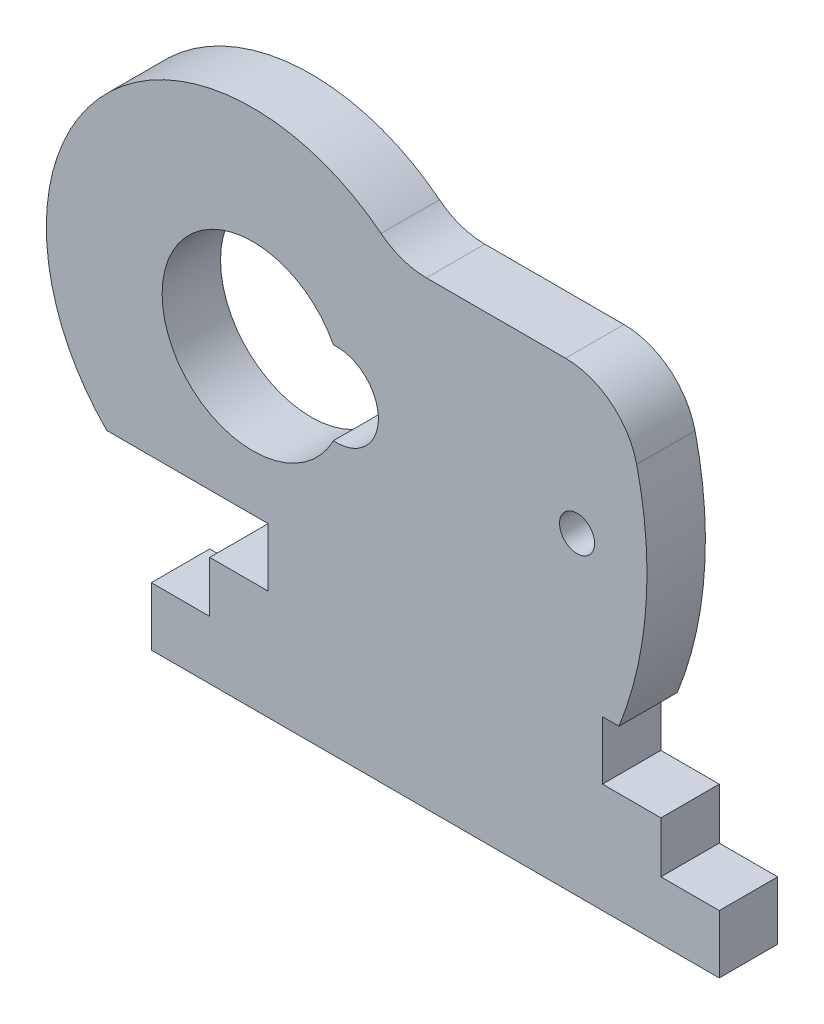
from build123d import *

# Parameters (mm, degrees)
SKETCH2_R           = 1.2
BOSS_EXTRUDE1_DEPTH = 4
FILLET1_R           = 5


with BuildPart() as part:
    # Sketch2 → Boss-Extrude1 (new body)
    with BuildSketch(Plane.XY):
        with BuildLine():
            Line((0, 4), (0, 0))
            Line((0, 0), (38.9, 0))
            Line((38.9, 0), (38.9, 4))
            Line((38.9, 4), (34.9, 4))
            Line((34.9, 4), (34.9, 7.5))
            Line((34.9, 7.5), (30.9, 7.5))
            Line((30.9, 7.5), (30.9, 11.5))
            Line((30.9, 11.5), (32.029872408, 11.5))
            ThreePointArc((32.029872408, 11.5), (33.95, 21.5), (32.029872408, 31.5))
            Line((32.029872408, 31.5), (16.95, 31.5))
            ThreePointArc((16.95, 31.5), (-3.05, 31.5), (-3.05, 11.5))
            Line((-3.05, 11.5), (8, 11.5))
            Line((8, 11.5), (8, 7.5))
            Line((8, 7.5), (4, 7.5))
            Line((4, 7.5), (4, 4))
            Line((4, 4), (0, 4))
        make_face()
        with BuildLine():
            ThreePointArc((12.472095652, 24.340873036), (15.55, 21.5), (12.472095652, 18.659126964))
            ThreePointArc((12.472095652, 18.659126964), (0.74, 21.5), (12.472095652, 24.340873036))
        make_face(mode=Mode.SUBTRACT)
        with Locations((29.16, 21.5)):
            Circle(SKETCH2_R, mode=Mode.SUBTRACT)
    extrude(amount=BOSS_EXTRUDE1_DEPTH)

    # Fillet1
    fillet1_edges = [part.edges().sort_by_distance(p)[0] for p in [
        (16.95, 31.5, 2),
        (32.029872408, 31.5, 2),
    ]]
    fillet(fillet1_edges, radius=FILLET1_R)


solid = part.part
